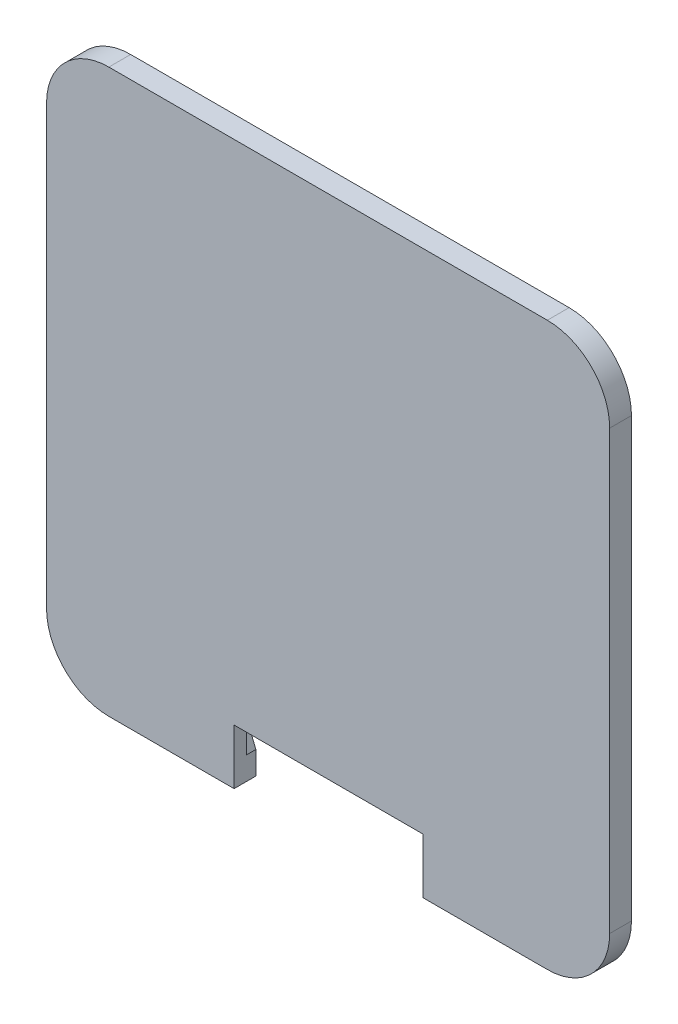
from build123d import *

# Parameters (mm, degrees)
BOSS_EXTRUDE1_DEPTH = 1.5
BOSS_EXTRUDE2_DEPTH = 2


with BuildPart() as part:
    # Sketch1 → Boss-Extrude1 (new body)
    with BuildSketch(Plane.XY):
        with BuildLine():
            Line((19.723160965, -30.122), (15.214660965, -41.425))
            Line((15.214660965, -41.425), (15.214660965, -45.122))
            Line((15.214660965, -45.122), (35.1855, -45.122))
            ThreePointArc((35.1855, -45.122), (42.256567812, -42.193067812), (45.1855, -35.122))
            Line((45.1855, -35.122), (45.1855, -30.122))
            Line((45.1855, -30.122), (45.1855, 35.122))
            ThreePointArc((45.1855, 35.122), (42.256567812, 42.193067812), (35.1855, 45.122))
            Line((35.1855, 45.122), (-35.1855, 45.122))
            ThreePointArc((-35.1855, 45.122), (-42.256567812, 42.193067812), (-45.1855, 35.122))
            Line((-45.1855, 35.122), (-45.1855, -30.122))
            Line((-45.1855, -30.122), (-45.1855, -35.122))
            ThreePointArc((-45.1855, -35.122), (-42.256567812, -42.193067812), (-35.1855, -45.122))
            Line((-35.1855, -45.122), (-15.086607553, -45.122))
            Line((-15.086607553, -45.122), (-15.086607553, -41.425))
            Line((-15.086607553, -41.425), (-19.722107553, -30.122))
            Line((-19.722107553, -30.122), (-24.9555, -30.122))
            ThreePointArc((-24.9555, -30.122), (-28.653668466, -28.590168466), (-30.1855, -24.892))
            Line((-30.1855, -24.892), (-30.1855, 24.892))
            ThreePointArc((-30.1855, 24.892), (-28.653668466, 28.590168466), (-24.9555, 30.122))
            Line((-24.9555, 30.122), (24.9555, 30.122))
            ThreePointArc((24.9555, 30.122), (28.653668466, 28.590168466), (30.1855, 24.892))
            Line((30.1855, 24.892), (30.1855, -24.892))
            ThreePointArc((30.1855, -24.892), (28.653668466, -28.590168466), (24.9555, -30.122))
            Line((24.9555, -30.122), (19.723160965, -30.122))
        make_face()
    extrude(amount=-BOSS_EXTRUDE1_DEPTH)

    # Sketch2 → Boss-Extrude2 (add)
    with BuildSketch(Plane.XY):
        with BuildLine():
            Line((-24.9555, 30.122), (24.9555, 30.122))
            ThreePointArc((24.9555, 30.122), (28.653668466, 28.590168466), (30.1855, 24.892))
            Line((30.1855, 24.892), (30.1855, -24.892))
            ThreePointArc((30.1855, -24.892), (28.653668466, -28.590168466), (24.9555, -30.122))
            Line((24.9555, -30.122), (19.723160965, -30.122))
            Line((19.723160965, -30.122), (15.214660965, -41.425))
            Line((15.214660965, -41.425), (15.214660965, -45.122))
            Line((15.214660965, -45.122), (35.1855, -45.122))
            ThreePointArc((35.1855, -45.122), (42.256567812, -42.193067812), (45.1855, -35.122))
            Line((45.1855, -35.122), (45.1855, 35.122))
            ThreePointArc((45.1855, 35.122), (42.256567812, 42.193067812), (35.1855, 45.122))
            Line((35.1855, 45.122), (-35.1855, 45.122))
            ThreePointArc((-35.1855, 45.122), (-42.256567812, 42.193067812), (-45.1855, 35.122))
            Line((-45.1855, 35.122), (-45.1855, -35.122))
            ThreePointArc((-45.1855, -35.122), (-42.256567812, -42.193067812), (-35.1855, -45.122))
            Line((-35.1855, -45.122), (-15.086607553, -45.122))
            Line((-15.086607553, -45.122), (-15.086607553, -41.425))
            Line((-15.086607553, -41.425), (-19.722107553, -30.122))
            Line((-19.722107553, -30.122), (-24.9555, -30.122))
            ThreePointArc((-24.9555, -30.122), (-28.653668466, -28.590168466), (-30.1855, -24.892))
            Line((-30.1855, -24.892), (-30.1855, 24.892))
            ThreePointArc((-30.1855, 24.892), (-28.653668466, 28.590168466), (-24.9555, 30.122))
        make_face()
        with BuildLine():
            Line((-19.722107553, -30.122), (-15.086607553, -41.425))
            Line((-15.086607553, -41.425), (-15.086607553, -36.275))
            Line((-15.086607553, -36.275), (15.214660965, -36.275))
            Line((15.214660965, -36.275), (15.214660965, -41.425))
            Line((15.214660965, -41.425), (19.723160965, -30.122))
            Line((19.723160965, -30.122), (24.9555, -30.122))
            ThreePointArc((24.9555, -30.122), (28.653668466, -28.590168466), (30.1855, -24.892))
            Line((30.1855, -24.892), (30.1855, 24.892))
            ThreePointArc((30.1855, 24.892), (28.653668466, 28.590168466), (24.9555, 30.122))
            Line((24.9555, 30.122), (-24.9555, 30.122))
            ThreePointArc((-24.9555, 30.122), (-28.653668466, 28.590168466), (-30.1855, 24.892))
            Line((-30.1855, 24.892), (-30.1855, -24.892))
            ThreePointArc((-30.1855, -24.892), (-28.653668466, -28.590168466), (-24.9555, -30.122))
            Line((-24.9555, -30.122), (-19.722107553, -30.122))
        make_face()
    extrude(amount=BOSS_EXTRUDE2_DEPTH)


solid = part.part
